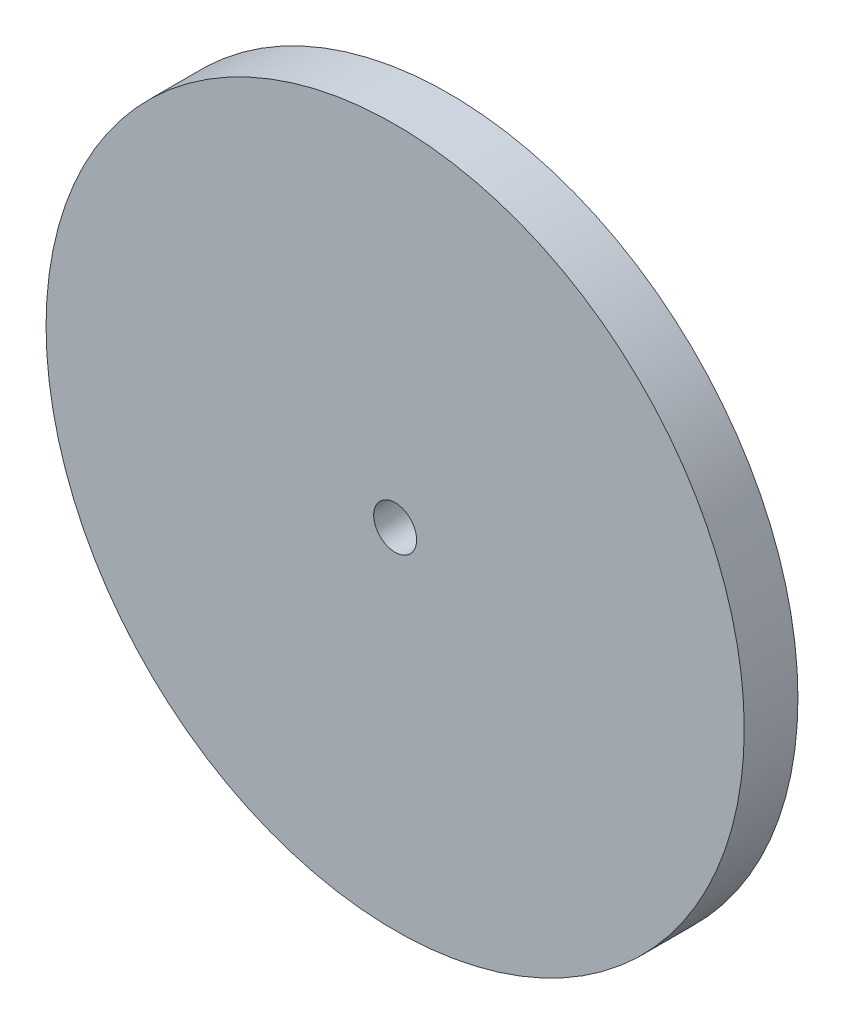
from build123d import *

# Parameters (mm, degrees)
SKETCH1_R           = 6.5
SKETCH1_R_2         = 0.4
BOSS_EXTRUDE1_DEPTH = 1


with BuildPart() as part:
    # Sketch1 → Boss-Extrude1 (new body)
    with BuildSketch(Plane.XY):
        Circle(SKETCH1_R)
        Circle(SKETCH1_R_2, mode=Mode.SUBTRACT)
    extrude(amount=BOSS_EXTRUDE1_DEPTH)


solid = part.part
